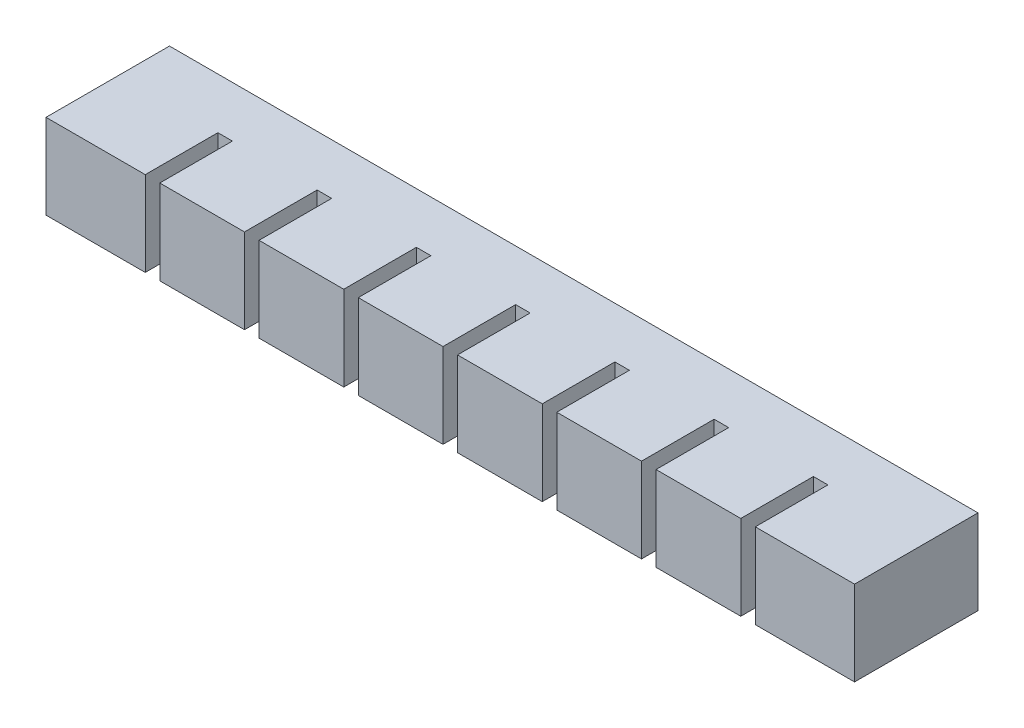
from build123d import *

# Parameters (mm, degrees)
SKETCH3_W           = 17.5
SKETCH3_H           = 17.5
BOSS_EXTRUDE2_DEPTH = 20
SKETCH4_W           = 9.5
SKETCH4_H           = 9.5
CUT_EXTRUDE1_DEPTH  = 16
SKETCH5_W           = 5
SKETCH5_H           = 17.5
BOSS_EXTRUDE3_DEPTH = 3
LPATTERN1_COUNT     = 8
LPATTERN1_PITCH     = 20.5
SKETCH6_W           = 15
SKETCH6_H           = 17.5
BOSS_EXTRUDE4_DEPTH = 3
SKETCH7_W           = 20
SKETCH7_H           = 17.5
BOSS_EXTRUDE5_DEPTH = 3
SKETCH8_W           = 134
SKETCH8_H           = 2
CUT_EXTRUDE2_DEPTH  = 2
SKETCH9_W           = 167
SKETCH9_H           = 17.5
BOSS_EXTRUDE6_DEPTH = 5.5


with BuildPart() as part:
    # Sketch3 → Boss-Extrude2 (new body)
    with BuildSketch(Plane.XY):
        with Locations((8.75, 8.75)):
            Rectangle(SKETCH3_W, SKETCH3_H)
    extrude(amount=BOSS_EXTRUDE2_DEPTH)

    # Sketch4 → Cut-Extrude1 (cut)
    with BuildSketch(Plane(origin=(0, 0, 0), x_dir=(-1, 0, 0), z_dir=(0, 0, -1))):
        with Locations((-8.75, 8.75)):
            Rectangle(SKETCH4_W, SKETCH4_H)
    extrude(amount=-CUT_EXTRUDE1_DEPTH, mode=Mode.SUBTRACT)

    # Sketch5 → Boss-Extrude3 (add)
    with BuildSketch(Plane.ZY):
        with Locations((2.5, 8.75)):
            Rectangle(SKETCH5_W, SKETCH5_H)
    extrude(amount=BOSS_EXTRUDE3_DEPTH)


with BuildPart() as lpattern1_1:
    # LPattern1: pattern copy
    add(part.part.moved(Location(Vector(-1, 0, 0) * (1 * LPATTERN1_PITCH))))


with BuildPart() as lpattern1_2:
    # LPattern1: pattern copy
    add(part.part.moved(Location(Vector(-1, 0, 0) * (2 * LPATTERN1_PITCH))))


with BuildPart() as lpattern1_3:
    # LPattern1: pattern copy
    add(part.part.moved(Location(Vector(-1, 0, 0) * (3 * LPATTERN1_PITCH))))


with BuildPart() as lpattern1_4:
    # LPattern1: pattern copy
    add(part.part.moved(Location(Vector(-1, 0, 0) * (4 * LPATTERN1_PITCH))))


with BuildPart() as lpattern1_5:
    # LPattern1: pattern copy
    add(part.part.moved(Location(Vector(-1, 0, 0) * (5 * LPATTERN1_PITCH))))


with BuildPart() as lpattern1_6:
    # LPattern1: pattern copy
    add(part.part.moved(Location(Vector(-1, 0, 0) * (6 * LPATTERN1_PITCH))))


with BuildPart() as lpattern1_7:
    # LPattern1: pattern copy
    add(part.part.moved(Location(Vector(-1, 0, 0) * (7 * LPATTERN1_PITCH))))


with BuildPart() as lpattern1_1_1:
    add(lpattern1_1.part)

    # Combine1: union LPattern1_2, LPattern1_3, part, LPattern1_4, LPattern1_5, LPattern1_6, LPattern1_7
    add(lpattern1_2.part)
    add(lpattern1_3.part)
    add(part.part)
    add(lpattern1_4.part)
    add(lpattern1_5.part)
    add(lpattern1_6.part)
    add(lpattern1_7.part)

    # Sketch6 → Boss-Extrude4 (add)
    with BuildSketch(Plane.ZY.offset(143.5)):
        with Locations((12.5, 8.75)):
            Rectangle(SKETCH6_W, SKETCH6_H)
    extrude(amount=BOSS_EXTRUDE4_DEPTH)

    # Sketch7 → Boss-Extrude5 (add)
    with BuildSketch(Plane(origin=(17.5, 0, 0), x_dir=(0, 0, -1), z_dir=(1, 0, 0))):
        with Locations((-10, 8.75)):
            Rectangle(SKETCH7_W, SKETCH7_H)
    extrude(amount=BOSS_EXTRUDE5_DEPTH)

    # Sketch8 → Cut-Extrude2 (cut)
    with BuildSketch(Plane(origin=(0, 0, 0), x_dir=(-1, 0, 0), z_dir=(0, 0, -1))):
        with Locations((63, 8.75)):
            Rectangle(SKETCH8_W, SKETCH8_H)
    extrude(amount=-CUT_EXTRUDE2_DEPTH, mode=Mode.SUBTRACT)

    # Sketch9 → Boss-Extrude6 (add)
    with BuildSketch(Plane(origin=(0, 0, 0), x_dir=(-1, 0, 0), z_dir=(0, 0, -1))):
        with Locations((63, 8.75)):
            Rectangle(SKETCH9_W, SKETCH9_H)
    extrude(amount=BOSS_EXTRUDE6_DEPTH)


solid = lpattern1_1_1.part
